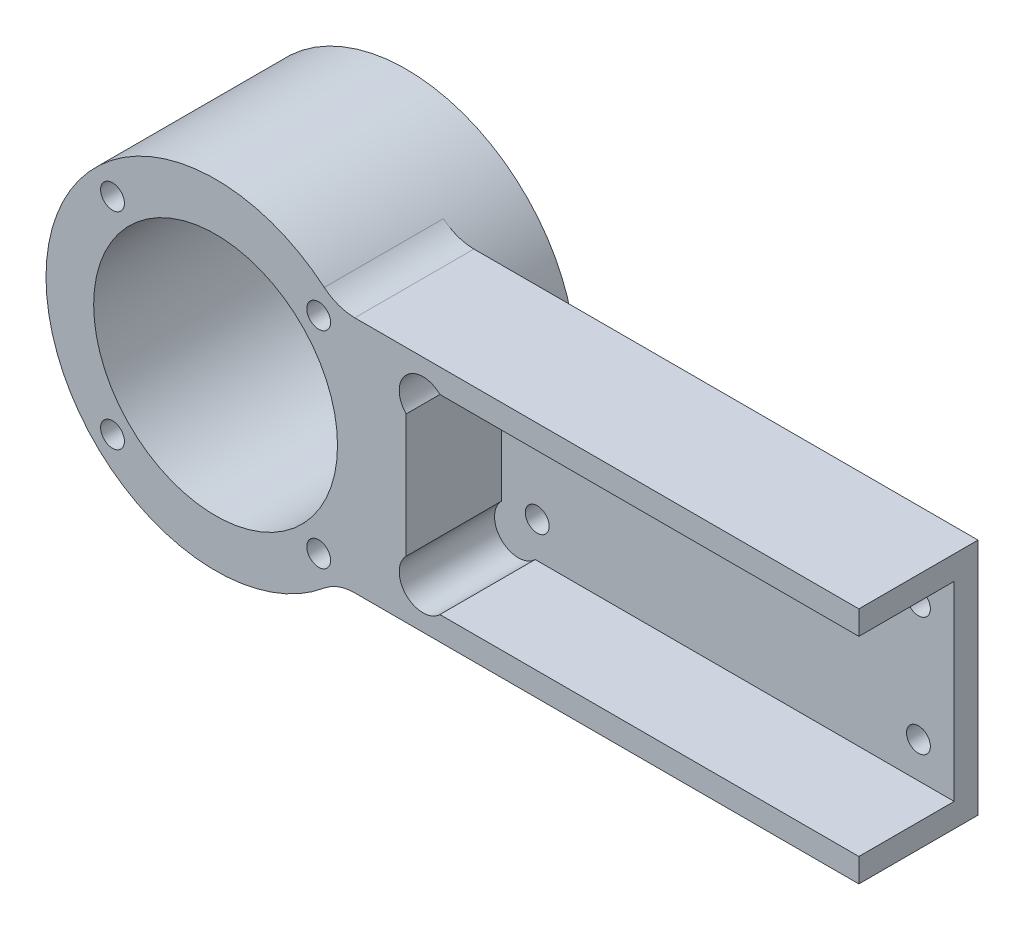
from build123d import *
from build123d.topology import SkipClean

# Parameters (mm, degrees)
SKETCH1_R               = 32.5
SKETCH1_W               = 120.65
SKETCH1_H               = 50.8
BOSS_EXTRUDE2_DEPTH     = 6.35
BOSS_EXTRUDE3_START     = 6.35
SKETCH1_3_R             = 32.5
BOSS_EXTRUDE3_DEPTH     = 25.4
SKETCH2_R               = 3.175
CUT_EXTRUDE1_DEPTH      = 180.118124432
CUT_EXTRUDE1_DEPTH_BACK = 180.118124432
SKETCH3_R               = 6.35
CUT_EXTRUDE2_DEPTH      = 25.4
FILLET1_R               = 12.7
SKETCH5_R               = 3.175
SKETCH5_R_2             = 32.5
BOSS_EXTRUDE6_DEPTH     = 19.05
SKETCH6_R               = 32.5
SKETCH6_R_2             = 27.5
BOSS_EXTRUDE7_DEPTH     = 2.54


with BuildPart() as part:
    # Sketch1 → Boss-Extrude2 (new body)
    with BuildSketch(Plane.XY):
        with BuildLine():
            Line((32.171066193, 31.75), (171.45, 31.75))
            Line((171.45, 31.75), (171.45, 25.4))
            Line((171.45, 25.4), (50.8, 25.4))
            Line((50.8, 25.4), (50.8, -25.4))
            Line((50.8, -25.4), (171.45, -25.4))
            Line((171.45, -25.4), (171.45, -31.75))
            Line((171.45, -31.75), (32.171066193, -31.75))
            ThreePointArc((32.171066193, -31.75), (-45.2, 0), (32.171066193, 31.75))
        make_face()
        Circle(SKETCH1_R, mode=Mode.SUBTRACT)
        with Locations((111.125, 0)):
            Rectangle(SKETCH1_W, SKETCH1_H)
    extrude(amount=BOSS_EXTRUDE2_DEPTH)

    # Sketch1_3 → Boss-Extrude3 (add)
    with BuildSketch(Plane.XY.offset(BOSS_EXTRUDE3_START)):
        with BuildLine():
            Line((32.171066193, 31.75), (171.45, 31.75))
            Line((171.45, 31.75), (171.45, 25.4))
            Line((171.45, 25.4), (50.8, 25.4))
            Line((50.8, 25.4), (50.8, -25.4))
            Line((50.8, -25.4), (171.45, -25.4))
            Line((171.45, -25.4), (171.45, -31.75))
            Line((171.45, -31.75), (32.171066193, -31.75))
            ThreePointArc((32.171066193, -31.75), (-45.2, 0), (32.171066193, 31.75))
        make_face()
        Circle(SKETCH1_3_R, mode=Mode.SUBTRACT)
    extrude(amount=BOSS_EXTRUDE3_DEPTH)

    # Sketch2 → Cut-Extrude1 (cut, two sides)
    with BuildSketch(Plane.XY.offset(6.35)) as cut_extrude1_sk:
        with Locations((60.325, 15.875)):
            Circle(SKETCH2_R)
        with Locations((161.925, 15.875)):
            Circle(SKETCH2_R)
        with Locations((161.925, -15.875)):
            Circle(SKETCH2_R)
        with Locations((60.325, -15.875)):
            Circle(SKETCH2_R)
        with Locations((27.471098449, 27.471098449)):
            Circle(SKETCH2_R)
        with Locations((27.471098449, -27.471098449)):
            Circle(SKETCH2_R)
        with Locations((-27.471098449, -27.471098449)):
            Circle(SKETCH2_R)
        with Locations((-27.471098449, 27.471098449)):
            Circle(SKETCH2_R)
    extrude(amount=CUT_EXTRUDE1_DEPTH, mode=Mode.SUBTRACT)
    extrude(cut_extrude1_sk.sketch, amount=-CUT_EXTRUDE1_DEPTH_BACK, mode=Mode.SUBTRACT)

    # Sketch3 → Cut-Extrude2 (cut)
    with BuildSketch(Plane.XY.offset(31.75)):
        with Locations((55.290128061, 20.909871939)):
            Circle(SKETCH3_R)
        with Locations((55.290128061, -20.909871939)):
            Circle(SKETCH3_R)
    extrude(amount=-CUT_EXTRUDE2_DEPTH, mode=Mode.SUBTRACT)

    # Fillet1
    fillet1_edges = [part.edges().sort_by_distance(p)[0] for p in [
        (32.171066193, -31.75, 15.875),
        (32.171066193, 31.75, 15.875),
    ]]
    fillet(fillet1_edges, radius=FILLET1_R)

    # Sketch5 → Boss-Extrude6 (add)
    with SkipClean():  # the faces are left unmerged after this step: merging them gives an invalid solid
        with BuildSketch(Plane(origin=(0, 0, 0), x_dir=(-1, 0, 0), z_dir=(0, 0, -1))):
            with BuildLine():
                ThreePointArc((-28.964426695, -34.700172712), (45.2, 0), (-28.964426695, 34.700172712))
                ThreePointArc((-28.964426695, 34.700172712), (-45.2, 0), (-28.964426695, -34.700172712))
            make_face()
            with Locations(Location((-27.471098449, -27.471098449, 0), (0, 0, 180))):
                Circle(SKETCH5_R, mode=Mode.SUBTRACT)
            with Locations(Location((27.471098449, -27.471098449, 0), (0, 0, 180))):
                Circle(SKETCH5_R, mode=Mode.SUBTRACT)
            with Locations(Location((27.471098449, 27.471098449, 0), (0, 0, 180))):
                Circle(SKETCH5_R, mode=Mode.SUBTRACT)
            with Locations(Location((-27.471098449, 27.471098449, 0), (0, 0, 180))):
                Circle(SKETCH5_R, mode=Mode.SUBTRACT)
            Circle(SKETCH5_R_2, mode=Mode.SUBTRACT)
        extrude(amount=BOSS_EXTRUDE6_DEPTH)

    # Sketch6 → Boss-Extrude7 (add)
    with SkipClean():  # the faces are left unmerged after this step: merging them gives an invalid solid
        with BuildSketch(Plane(origin=(0, 0, -19.05), x_dir=(-1, 0, 0), z_dir=(0, 0, -1))):
            Circle(SKETCH6_R)
            Circle(SKETCH6_R_2, mode=Mode.SUBTRACT)
        extrude(amount=-BOSS_EXTRUDE7_DEPTH)


solid = part.part
